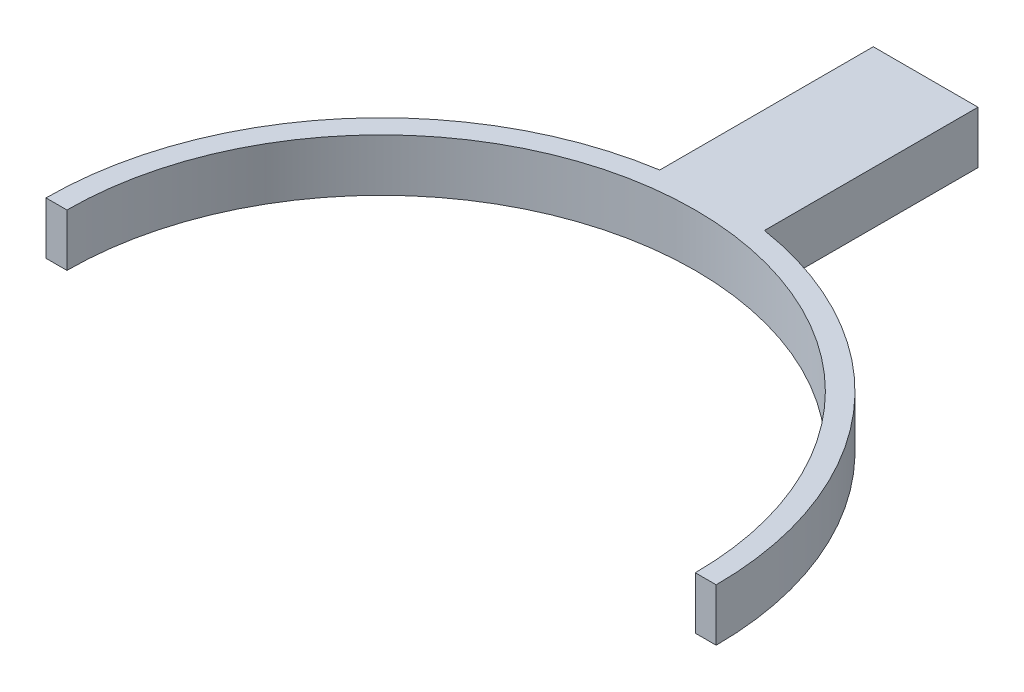
from build123d import *

# Parameters (mm, degrees)
EXTRUDE_1_DEPTH = 5
EXTRUDE_2_DEPTH = 5


with BuildPart() as part:
    # 草图1 → 凸台-拉伸1 (new body)
    with BuildSketch(Plane(origin=(0, 0, 0), x_dir=(1, 0, 0), z_dir=(0, 1, 0))):
        with BuildLine():
            Line((-32, 0), (-30, 0))
            ThreePointArc((-30, 0), (0, 30), (30, 0))
            Line((30, 0), (32, 0))
            ThreePointArc((32, 0), (0, 32), (-32, 0))
        make_face()
    extrude(amount=EXTRUDE_1_DEPTH)

    # 草图2 → 凸台-拉伸2 (add)
    with BuildSketch(Plane(origin=(0, 0, 0), x_dir=(1, 0, 0), z_dir=(0, 1, 0))):
        Polygon((5, 52), (0, 52), (-5, 52), (-5, 31), (5, 31), align=None)
    extrude(amount=EXTRUDE_2_DEPTH)


solid = part.part
